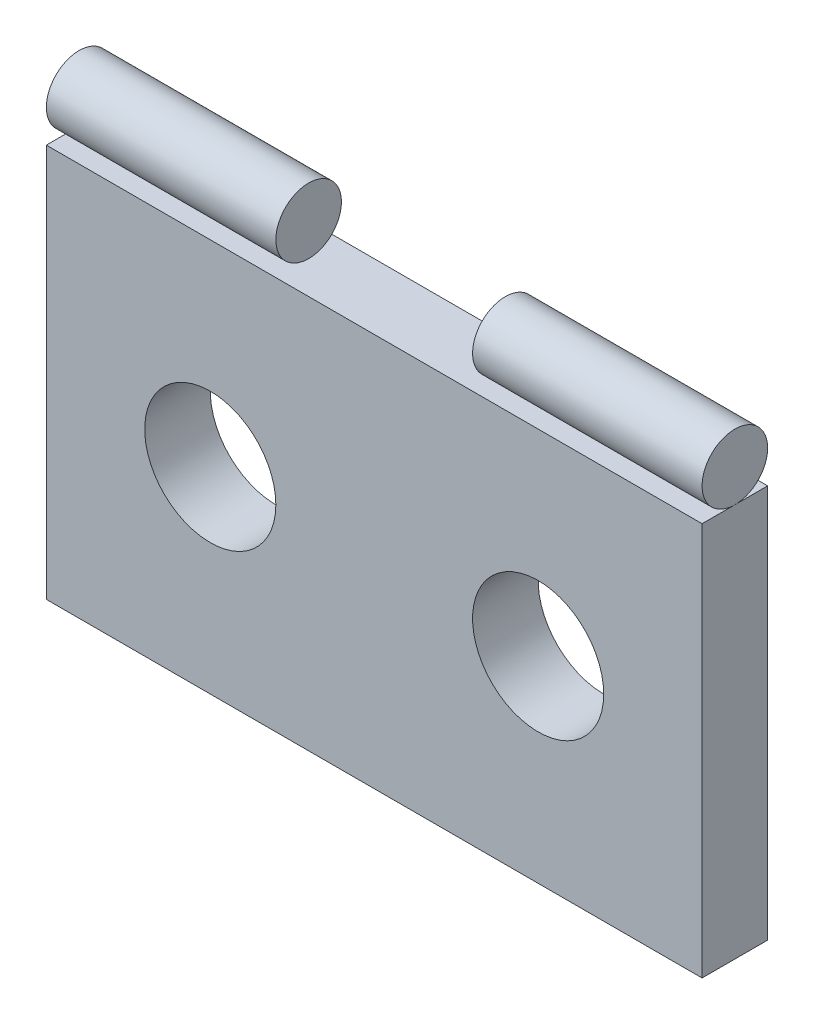
from build123d import *

# Parameters (mm, degrees)
ESQUISSE1_W                  = 50
ESQUISSE1_H                  = 30
BOSS_EXTRU_1_DEPTH           = 5
ESQUISSE2_R                  = 5
ENL_V_MAT_EXTRU_1_DEPTH      = 59.523499554
ESQUISSE3_R                  = 2.5
BOSS_EXTRU_2_DEPTH           = 50
ENL_V_MAT_EXTRU_4_DEPTH      = 50
ENL_V_MAT_EXTRU_4_DEPTH_BACK = 50
ESQUISSE4_W                  = 15
ESQUISSE4_H                  = 5


with BuildPart() as part:
    # Esquisse1 → Boss.-Extru.1 (new body)
    with BuildSketch(Plane.XY):
        with Locations((25, 15)):
            Rectangle(ESQUISSE1_W, ESQUISSE1_H)
    extrude(amount=BOSS_EXTRU_1_DEPTH)

    # Esquisse2 → Enlèv. mat.-Extru.1 (cut, through all)
    with BuildSketch(Plane.XY.offset(5)):
        with Locations((12.5, 15)):
            Circle(ESQUISSE2_R)
        with Locations((37.5, 15)):
            Circle(ESQUISSE2_R)
    extrude(amount=-ENL_V_MAT_EXTRU_1_DEPTH, mode=Mode.SUBTRACT)


with BuildPart() as body_2:
    # Esquisse3 → Boss.-Extru.2 (new body)
    with BuildSketch(Plane(origin=(50, 0, 0), x_dir=(0, 0, -1), z_dir=(1, 0, 0))):
        with Locations((-2.5, 32.5)):
            Circle(ESQUISSE3_R)
    extrude(amount=-BOSS_EXTRU_2_DEPTH)

    # Esquisse4 → Enlèv. mat.-Extru.4 (cut, two sides: drawn at the far end of the back side and taken through both)
    with BuildSketch(Plane.XY.offset(5).offset(-ENL_V_MAT_EXTRU_4_DEPTH_BACK)):
        with Locations((25, 32.5)):
            Rectangle(ESQUISSE4_W, ESQUISSE4_H)
    extrude(amount=ENL_V_MAT_EXTRU_4_DEPTH + ENL_V_MAT_EXTRU_4_DEPTH_BACK, mode=Mode.SUBTRACT)


with BuildPart() as enl_v_mat_extru_4_piece_1:
    # of the separate pieces the step leaves, piece 1, a body of its own (enl_v_mat_extru_4_pieces)
    add(body_2.part.solids().sort_by_distance((17.5, 32.5, 0))[0])


with BuildPart() as enl_v_mat_extru_4_piece_2:
    # of the separate pieces the step leaves, piece 2, a body of its own (enl_v_mat_extru_4_pieces)
    add(body_2.part.solids().sort_by_distance((50, 32.5, 0))[0])


solid = Compound([part.part, enl_v_mat_extru_4_piece_1.part, enl_v_mat_extru_4_piece_2.part])
